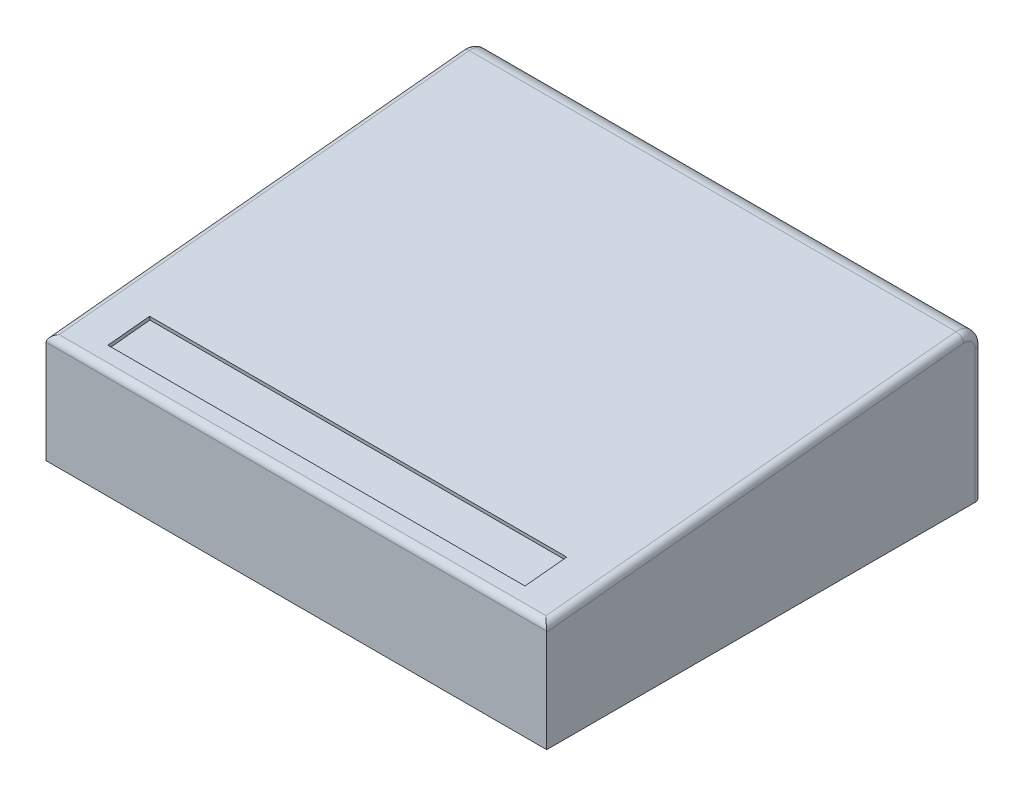
from build123d import *

# Parameters (mm, degrees)
BOSS_EXTRUDE1_DEPTH = 18.25625
FILLET1_R           = 0.635
FILLET2_R           = 0.254
SKETCH2_W           = 15.20825
SKETCH2_H           = 1.528516132
CUT_EXTRUDE1_DEPTH  = 0.127


with BuildPart() as part:
    # Sketch1 → Boss-Extrude1 (new body)
    with BuildSketch(Plane(origin=(0, 0, 0), x_dir=(0, 0, -1), z_dir=(1, 0, 0))):
        Polygon((0, 0), (15.875, 0), (15.875, 5.55625), (0, 3.96875), align=None)
    extrude(amount=BOSS_EXTRUDE1_DEPTH)

    # Fillet1
    fillet1_edges = [part.edges().sort_by_distance(p)[0] for p in [
        (9.128125, 5.55625, -15.875),
    ]]
    fillet(fillet1_edges, radius=FILLET1_R)

    # Fillet2
    fillet2_edges = [part.edges().sort_by_distance(p)[0] for p in [
        (18.25625, 2.427291449, -15.875),
        (0, 4.727590757, -7.588407569),
        (18.25625, 4.727590757, -7.588407569),
        (0, 5.325405257, -15.666088379),
        (18.25625, 5.325405257, -15.666088379),
        (0, 2.427291449, -15.875),
        (9.128125, 3.96875, 0),
    ]]
    fillet(fillet2_edges, radius=FILLET2_R)

    # Sketch2 → Cut-Extrude1 (cut)
    with BuildSketch(Plane(origin=(0, 3.929455446, 0.392945545), x_dir=(1, 0, 0), z_dir=(0, 0.99503719, 0.099503719))):
        with Locations((9.128125, 1.894772226)):
            Rectangle(SKETCH2_W, SKETCH2_H)
    extrude(amount=-CUT_EXTRUDE1_DEPTH, mode=Mode.SUBTRACT)


solid = part.part
